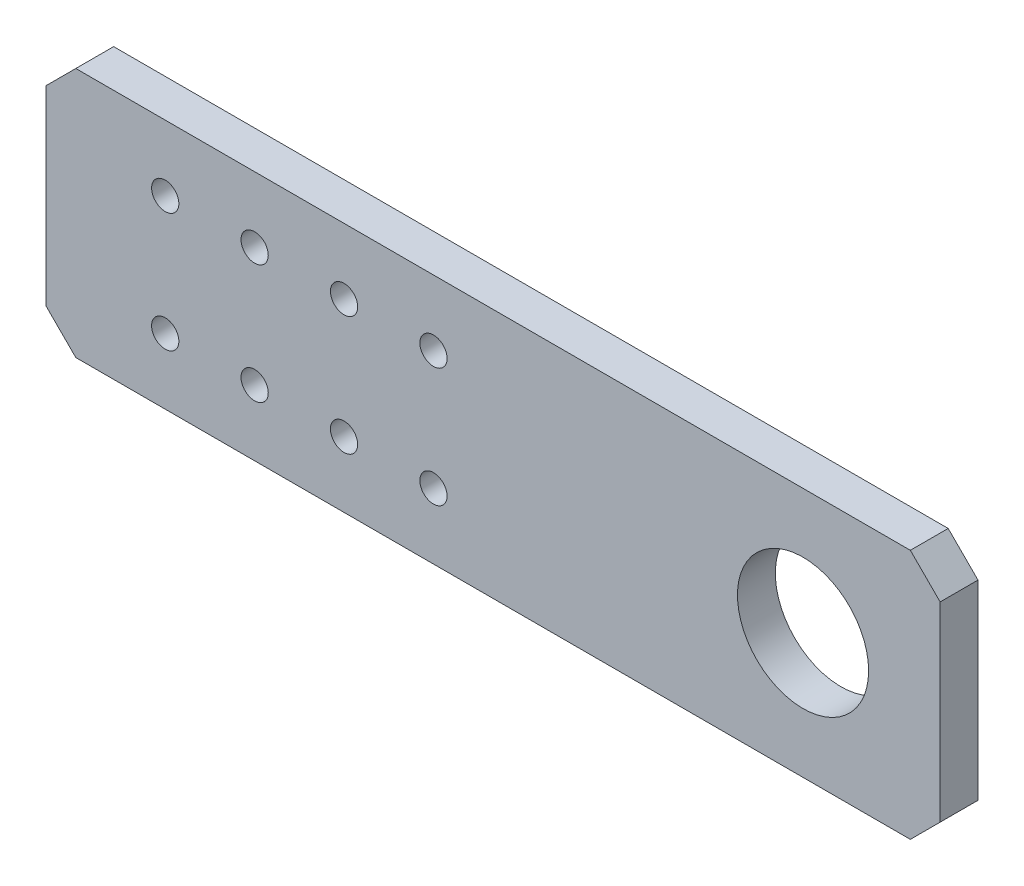
from build123d import *

# Parameters (mm, degrees)
SKETCH1_W           = 205
SKETCH1_H           = 42
BOSS_EXTRUDE1_DEPTH = 6.35
SKETCH4_R           = 11
CUT_EXTRUDE3_DEPTH  = 7.35
CHAMFER1_SIZE       = 5
SKETCH5_R           = 11
CUT_EXTRUDE4_DEPTH  = 25
SKETCH13_R          = 11
SKETCH13_R_2        = 2.286
CUT_EXTRUDE12_DEPTH = 10


with BuildPart() as part:
    # Sketch1 → Boss-Extrude1 (new body)
    with BuildSketch(Plane.XY):
        Rectangle(SKETCH1_W, SKETCH1_H)
    extrude(amount=BOSS_EXTRUDE1_DEPTH)

    # Sketch4 → Cut-Extrude3 (cut, through all)
    with BuildSketch(Plane.XY.offset(6.35)):
        with Locations((-78.5, 0)):
            Circle(SKETCH4_R)
    extrude(amount=-CUT_EXTRUDE3_DEPTH, mode=Mode.SUBTRACT)

    # Chamfer1
    chamfer1_edges = [part.edges().sort_by_distance(p)[0] for p in [
        (102.5, -21, 3.175),
        (-102.5, -21, 3.175),
        (-102.5, 21, 3.175),
        (102.5, 21, 3.175),
    ]]
    chamfer(chamfer1_edges, length=CHAMFER1_SIZE)

    # Sketch5 → Cut-Extrude4 (cut)
    with BuildSketch(Plane.XY.offset(6.35)):
        with Locations((79.5, 0)):
            Circle(SKETCH5_R)
    extrude(amount=-CUT_EXTRUDE4_DEPTH, mode=Mode.SUBTRACT)

    # Sketch13 → Cut-Extrude12 (cut)
    with BuildSketch(Plane.XY.offset(6.35)):
        Polygon((-47.5, -16), (-47.5, 16), (-42.5, 21), (-97.5, 21), (-102.5, 16), (-102.5, -16), (-97.5, -21), (-42.5, -21), align=None)
        with Locations((-78.5, 0)):
            Circle(SKETCH13_R, mode=Mode.SUBTRACT)
        with Locations((-27.5, 10)):
            Circle(SKETCH13_R_2)
        with Locations((-12.5, 10)):
            Circle(SKETCH13_R_2)
        with Locations((-12.5, -10)):
            Circle(SKETCH13_R_2)
        with Locations((-27.5, -10)):
            Circle(SKETCH13_R_2)
        with Locations((2.5, 10)):
            Circle(SKETCH13_R_2)
        with Locations((17.5, 10)):
            Circle(SKETCH13_R_2)
        with Locations((17.5, -10)):
            Circle(SKETCH13_R_2)
        with Locations((2.5, -10)):
            Circle(SKETCH13_R_2)
    extrude(amount=-CUT_EXTRUDE12_DEPTH, mode=Mode.SUBTRACT)


solid = part.part
